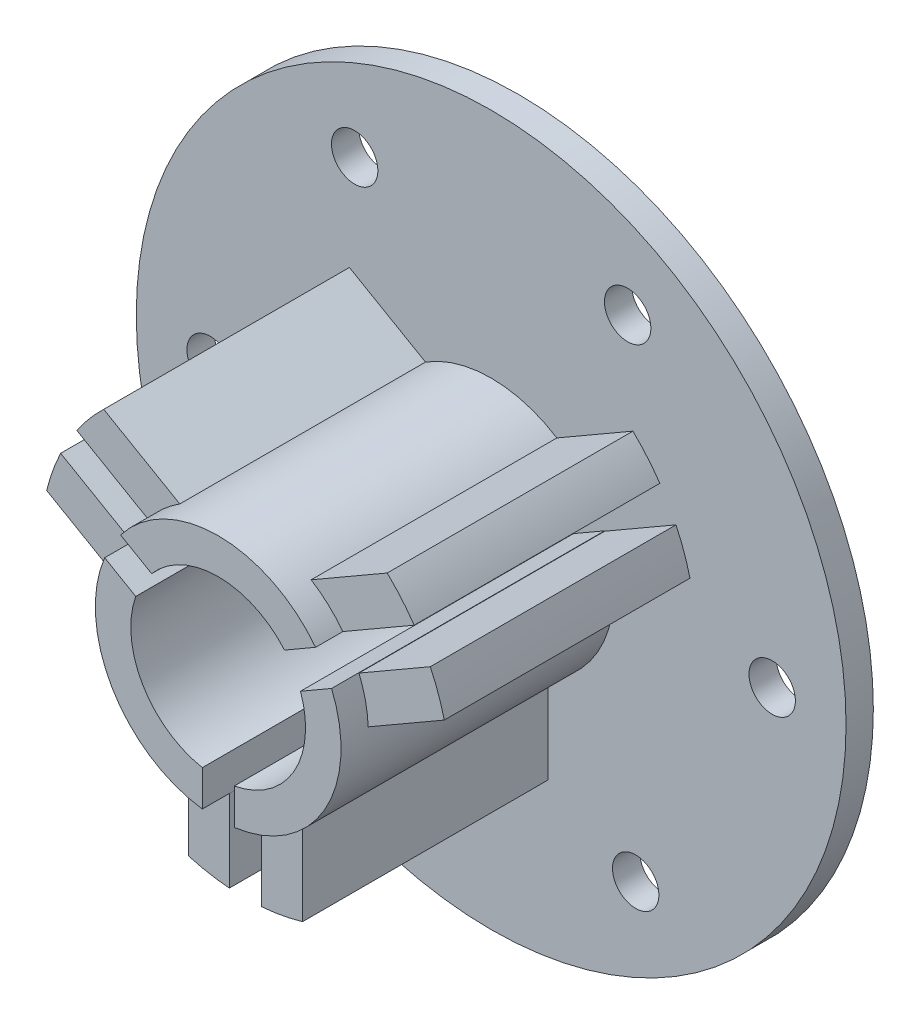
from build123d import *

# Parameters (mm, degrees)
SKETCH1_R            = 65
BOSS_EXTRUDE1_DEPTH  = 5
BOSS_EXTRUDE2_DEPTH  = 50
BOSS_EXTRUDE3_DEPTH  = 45
BOSS_EXTRUDE4_DEPTH  = 45
BOSS_EXTRUDE6_DEPTH  = 45
BOSS_EXTRUDE7_DEPTH  = 45
BOSS_EXTRUDE9_DEPTH  = 45
BOSS_EXTRUDE10_DEPTH = 45
SKETCH11_R           = 4.25
CUT_EXTRUDE1_DEPTH   = 10


with BuildPart() as part:
    # Sketch1 → Boss-Extrude1 (new body)
    with BuildSketch(Plane.XY.offset(5)):
        Circle(SKETCH1_R)
    extrude(amount=-BOSS_EXTRUDE1_DEPTH)

    # Sketch2 → Boss-Extrude2 (add)
    with BuildSketch(Plane.XY.offset(5)):
        with BuildLine():
            Line((-2.896618782, -15.740746549), (-2.896618782, -22.312767637))
            ThreePointArc((-2.896618782, -22.312767637), (-19.472098251, -11.273304294), (-20.792365892, 8.598111457))
            Line((-20.792365892, 8.598111457), (-15.098298122, 5.310639897))
            ThreePointArc((-15.098298122, 5.310639897), (-13.847182977, -8.026021796), (-2.896618782, -15.740746549))
        make_face()
        with BuildLine():
            Line((17.842365892, 13.707661339), (12.148298122, 10.420189779))
            ThreePointArc((12.148298122, 10.420189779), (-0.027147278, 16.005023127), (-12.183576995, 10.378918724))
            Line((-12.183576995, 10.378918724), (-17.875114212, 13.664929269))
            ThreePointArc((-17.875114212, 13.664929269), (-0.026918777, 22.499983897), (17.842365892, 13.707661339))
        make_face()
        with BuildLine():
            Line((2.95, -22.305772795), (2.95, -15.730829675))
            ThreePointArc((2.95, -15.730829675), (13.874330255, -7.979001331), (15.080195777, 5.361827824))
            Line((15.080195777, 5.361827824), (20.771732993, 8.647838368))
            ThreePointArc((20.771732993, 8.647838368), (19.499017028, -11.226679604), (2.95, -22.305772795))
        make_face()
    extrude(amount=BOSS_EXTRUDE2_DEPTH)

    # Sketch3 → Boss-Extrude3 (add)
    with BuildSketch(Plane.XY.offset(5)):
        with BuildLine():
            Line((-33.850308879, 16.137118355), (-20.792365892, 8.598111457))
            ThreePointArc((-20.792365892, 8.598111457), (-21.975466771, 4.82999588), (-22.481466179, 0.913059924))
            Line((-22.481466179, 0.913059924), (-36.414511458, 8.957307367))
            ThreePointArc((-36.414511458, 8.957307367), (-35.315346037, 12.612546701), (-33.850308879, 16.137118355))
        make_face()
    extrude(amount=BOSS_EXTRUDE3_DEPTH)

    # Sketch4 → Boss-Extrude4 (add)
    with BuildSketch(Plane.XY.offset(5)):
        with BuildLine():
            Line((-10.45, -36.014545673), (-10.45, -19.926050788))
            ThreePointArc((-10.45, -19.926050788), (-6.804834253, -21.446310424), (-2.95, -22.305772795))
            Line((-2.95, -22.305772795), (-2.95, -37.383786593))
            ThreePointArc((-2.95, -37.383786593), (-6.734887169, -36.890260162), (-10.45, -36.014545673))
        make_face()
    extrude(amount=BOSS_EXTRUDE4_DEPTH)

    # Sketch6 → Boss-Extrude6 (add)
    with BuildSketch(Plane.XY.offset(5)):
        with BuildLine():
            Line((30.900308879, 21.246668237), (17.842365892, 13.707661339))
            ThreePointArc((17.842365892, 13.707661339), (15.170632518, 16.616314543), (12.031466179, 19.012990863))
            Line((12.031466179, 19.012990863), (25.964511458, 27.057238306))
            ThreePointArc((25.964511458, 27.057238306), (28.580458868, 24.277713461), (30.900308879, 21.246668237))
        make_face()
    extrude(amount=BOSS_EXTRUDE6_DEPTH)

    # Sketch7 → Boss-Extrude7 (add)
    with BuildSketch(Plane.XY.offset(5)):
        with BuildLine():
            Line((-25.964511458, 27.057238306), (-12.031466179, 19.012990863))
            ThreePointArc((-12.031466179, 19.012990863), (-15.170632518, 16.616314543), (-17.842365892, 13.707661339))
            Line((-17.842365892, 13.707661339), (-30.900308879, 21.246668237))
            ThreePointArc((-30.900308879, 21.246668237), (-28.580458868, 24.277713461), (-25.964511458, 27.057238306))
        make_face()
    extrude(amount=BOSS_EXTRUDE7_DEPTH)

    # Sketch9 → Boss-Extrude9 (add)
    with BuildSketch(Plane.XY.offset(5)):
        with BuildLine():
            Line((2.95, -37.383786593), (2.95, -22.305772795))
            ThreePointArc((2.95, -22.305772795), (6.804834253, -21.446310424), (10.45, -19.926050788))
            Line((10.45, -19.926050788), (10.45, -36.014545673))
            ThreePointArc((10.45, -36.014545673), (6.734887169, -36.890260162), (2.95, -37.383786593))
        make_face()
    extrude(amount=BOSS_EXTRUDE9_DEPTH)

    # Sketch10 → Boss-Extrude10 (add)
    with BuildSketch(Plane.XY.offset(5)):
        with BuildLine():
            Line((36.414511458, 8.957307367), (22.481466179, 0.913059924))
            ThreePointArc((22.481466179, 0.913059924), (21.975466771, 4.82999588), (20.792365892, 8.598111457))
            Line((20.792365892, 8.598111457), (33.850308879, 16.137118355))
            ThreePointArc((33.850308879, 16.137118355), (35.315346037, 12.612546701), (36.414511458, 8.957307367))
        make_face()
    extrude(amount=BOSS_EXTRUDE10_DEPTH)

    # Sketch11 → Cut-Extrude1 (cut)
    with BuildSketch(Plane.XY.offset(5)):
        with Locations((-25, 45)):
            Circle(SKETCH11_R)
        with Locations((25, 45)):
            Circle(SKETCH11_R)
        with Locations((26.47114317, -44.150635095)):
            Circle(SKETCH11_R)
        with Locations((51.47114317, -0.849364905)):
            Circle(SKETCH11_R)
        with Locations((-51.47114317, -0.849364905)):
            Circle(SKETCH11_R)
        with Locations((-26.47114317, -44.150635095)):
            Circle(SKETCH11_R)
    extrude(amount=-CUT_EXTRUDE1_DEPTH, mode=Mode.SUBTRACT)


solid = part.part
